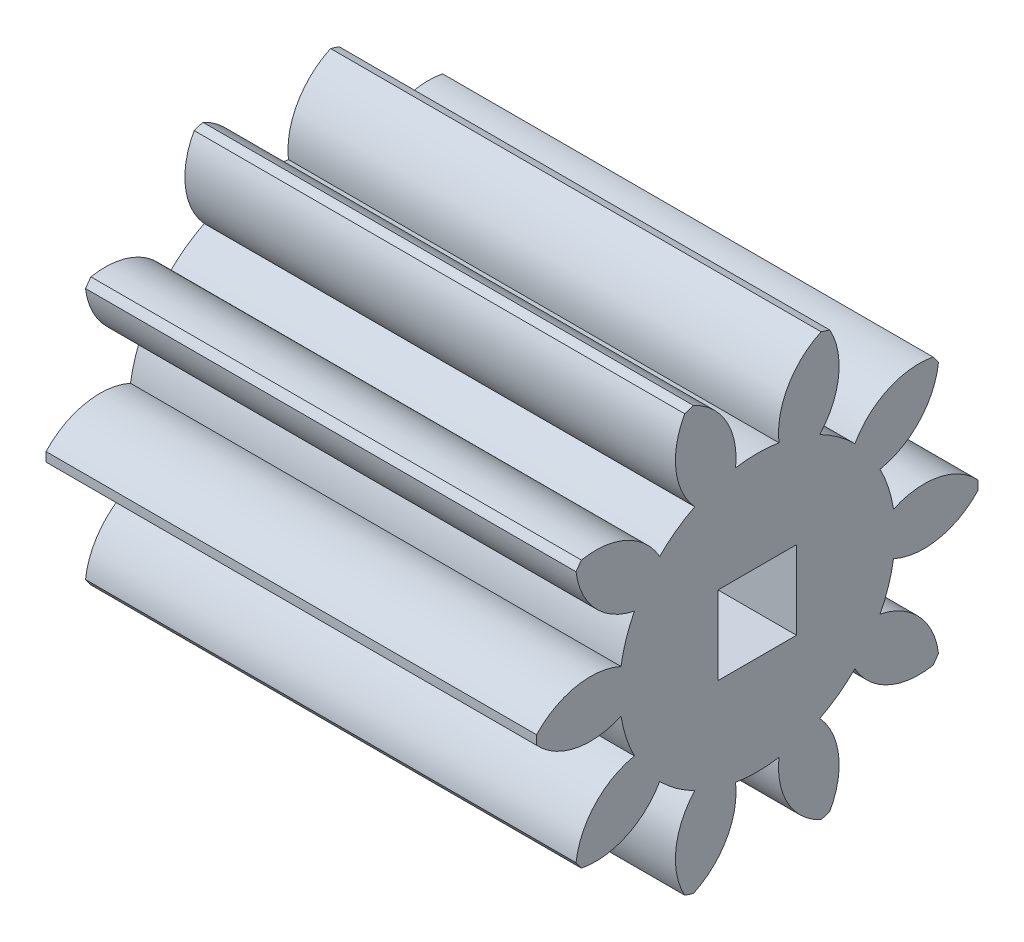
from build123d import *

# Parameters (mm, degrees)
BASPROSKE_W        = 20
BASPROSKE_H        = 9
TOOTHCUT_DEPTH     = 24.706539182
TEETHCUTS_COUNT    = 10
TEETHCUTS_ANGLE    = 324
BORSKE_R           = 1.5
BORE_DEPTH         = 50.0000508
SKETCH1_W          = 3.2
SKETCH1_H          = 3.2
CUT_EXTRUDE1_DEPTH = 10


with BuildPart() as part:
    # BasProSke → Base-Revolve (revolve)
    with BuildSketch(Plane(origin=(0, 0, 0), x_dir=(1, 0, 0), z_dir=(0, 1, 0)), mode=Mode.PRIVATE) as base_revolve_sk:
        with Locations((10, 4.5)):
            Rectangle(BASPROSKE_W, BASPROSKE_H)
    revolve(base_revolve_sk.sketch.rotate(Axis((-10, 0, 0), (1, 0, 0)), 180), axis=Axis((-10, 0, 0), (1, 0, 0)))

    # TooCutSke → ToothCut (cut, through all)
    with BuildSketch(Plane(origin=(0, 0, 0), x_dir=(0, 0, -1), z_dir=(1, 0, 0))):
        with BuildLine():
            ThreePointArc((0.883878355, 5.554109745), (0, 5.624), (-0.883878355, 5.554109745))
            ThreePointArc((-0.883878355, 5.554109745), (-1.258245767, 7.379188248), (-2.637816971, 8.631324741))
            ThreePointArc((-2.637816971, 8.631324741), (0, 9.0254), (2.637816971, 8.631324741))
            ThreePointArc((2.637816971, 8.631324741), (1.258245767, 7.379188248), (0.883878355, 5.554109745))
        make_face()
    toothcut = extrude(amount=TOOTHCUT_DEPTH, mode=Mode.SUBTRACT)

    # TeethCuts: ToothCut ×10 about axis
    teethcuts_axis = Axis((-10, 0, 0), (1, 0, 0))
    for i in range(1, TEETHCUTS_COUNT):
        add(toothcut.rotate(teethcuts_axis, i * TEETHCUTS_ANGLE / (TEETHCUTS_COUNT - 1)), mode=Mode.SUBTRACT)

    # BorSke → Bore (cut, symmetric)
    with BuildSketch(Plane(origin=(0, 0, 0), x_dir=(0, 0, -1), z_dir=(1, 0, 0))):
        with Locations(Location((0, 0, 0), (0, 0, 180))):
            Circle(BORSKE_R)
    extrude(amount=BORE_DEPTH, both=True, mode=Mode.SUBTRACT)

    # Sketch1 → Cut-Extrude1 (cut)
    with BuildSketch(Plane(origin=(20, 0, 0), x_dir=(0, 0, -1), z_dir=(1, 0, 0))):
        Rectangle(SKETCH1_W, SKETCH1_H)
    extrude(amount=-CUT_EXTRUDE1_DEPTH, mode=Mode.SUBTRACT)


solid = part.part
